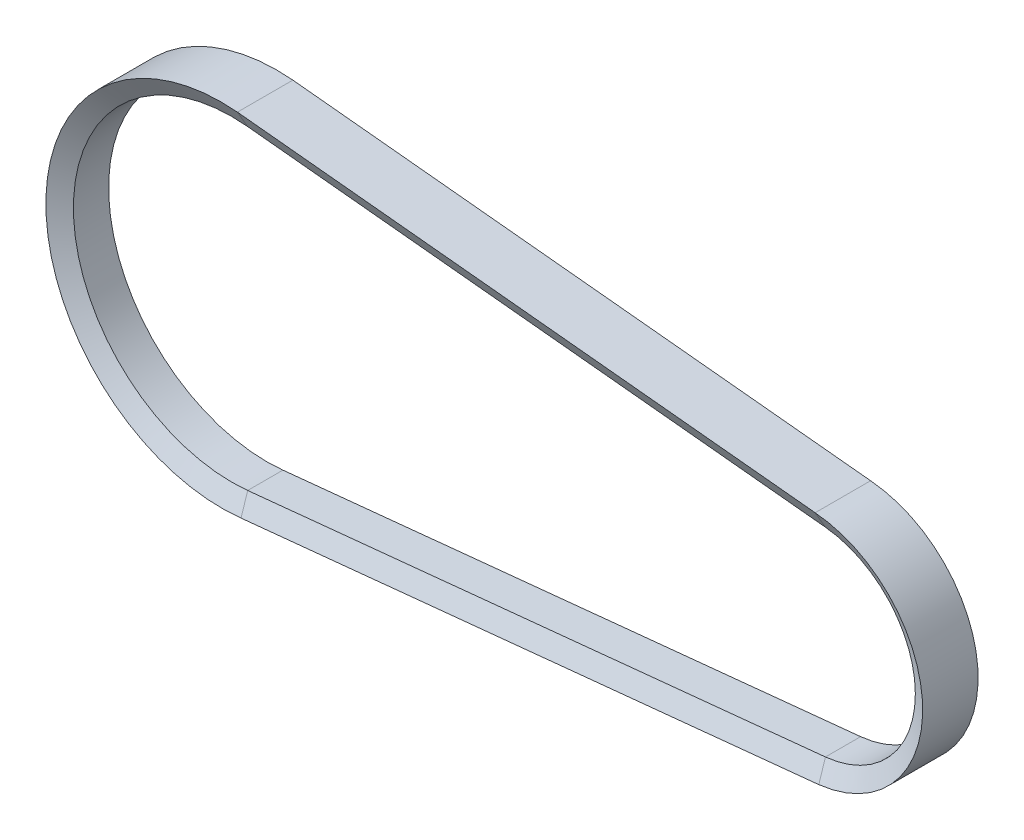
from build123d import *


with BuildPart() as part:
    # Sweep1: sweep along a path in Sketch2
    with BuildLine(Plane.XY) as sweep1_path:
        Line((5.4, 53.729321604), (203.4, 33.829572862))
        ThreePointArc((203.4, 33.829572862), (234, 0), (203.4, -33.829572862))
        Line((203.4, -33.829572862), (5.4, -53.729321604))
        ThreePointArc((5.4, -53.729321604), (-54, 0), (5.4, 53.729321604))
    # Sketch3 → Sweep1 (sweep)
    with BuildSketch(Plane(origin=(5.4, 0, 0), x_dir=(0, 0, -1), z_dir=(1, 0, 0))):
        Polygon((-6.035, 54), (6.035, 54), (9.499101615, 60), (-9.499101615, 60), align=None)
    sweep(path=sweep1_path.line)


solid = part.part
